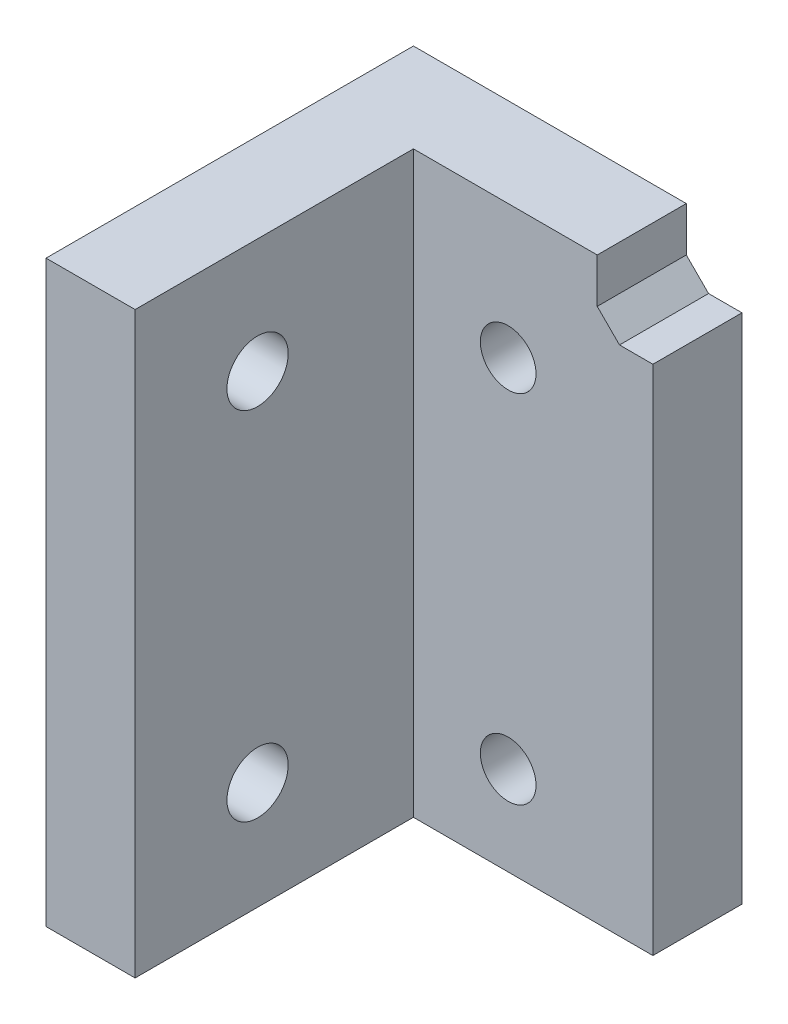
from build123d import *

# Parameters (mm, degrees)
SKETCH1_W               = 24.51
SKETCH1_H               = 148
BOSS_EXTRUDE1_DEPTH     = 8
SKETCH2_W               = 8
SKETCH2_H               = 148
BOSS_EXTRUDE2_DEPTH     = 25
SKETCH4_W               = 20.3
SKETCH4_H               = 36.8
BOSS_EXTRUDE3_DEPTH     = 8
SKETCH5_W               = 23
SKETCH5_H               = 6
BOSS_EXTRUDE4_DEPTH     = 25
CUT_EXTRUDE2_REACH      = 151.752
SKETCH6_R               = 2
RIB1_REACH              = 159.03
SKETCH8_WALL_W          = 336.456302216
SKETCH8_WALL_H          = 3
MIRROR2_COPY_1_REACH    = 159.03
MIRROR2_COPY_1_SKETCH_W = 336.456302216
MIRROR2_COPY_1_SKETCH_H = 3
SKETCH3_R               = 2.5
CUT_EXTRUDE1_DEPTH      = 10
SKETCH12_R              = 2.75
CUT_EXTRUDE3_DEPTH      = 8
SKETCH13_W              = 5
SKETCH13_H              = 46
BOSS_EXTRUDE5_DEPTH     = 8
SKETCH14_W              = 3
SKETCH14_H              = 17
BOSS_EXTRUDE6_DEPTH     = 8
CHAMFER1_SIZE           = 2
CHAMFER2_SIZE           = 6
CHAMFER2_SIZE2          = 4.047051101
SKETCH15_W              = 33
SKETCH15_H              = 96
CUT_EXTRUDE4_DEPTH      = 45


with BuildPart() as part:
    # Sketch1 → Boss-Extrude1 (new body)
    with BuildSketch(Plane.XY):
        with Locations((-12.255, 74)):
            Rectangle(SKETCH1_W, SKETCH1_H)
    extrude(amount=BOSS_EXTRUDE1_DEPTH)

    # Sketch2 → Boss-Extrude2 (add)
    with BuildSketch(Plane.XY.offset(8)):
        with Locations((-20.51, 74)):
            Rectangle(SKETCH2_W, SKETCH2_H)
    extrude(amount=BOSS_EXTRUDE2_DEPTH)

    # Sketch4 → Boss-Extrude3 (add)
    with BuildSketch(Plane(origin=(0, 0, 0), x_dir=(-1, 0, 0), z_dir=(0, 0, -1))):
        with Locations((-10.15, 129.6)):
            Rectangle(SKETCH4_W, SKETCH4_H)
    extrude(amount=-BOSS_EXTRUDE3_DEPTH)

    # Sketch5 → Boss-Extrude4 (add)
    with BuildSketch(Plane.XY.offset(8)):
        with Locations((8.8, 118.2)):
            Rectangle(SKETCH5_W, SKETCH5_H)
        with Locations((8.8, 141)):
            Rectangle(SKETCH5_W, SKETCH5_H)
    extrude(amount=BOSS_EXTRUDE4_DEPTH)

    # Cut-Extrude2: up to this face of the body (flat: up to its plane)
    cut_extrude2_end = Plane(part.part.faces().sort_by_distance((8.8, 115.2, 20.5))[0])
    # Sketch6 → Cut-Extrude2 (cut, up to the picked face)
    with BuildSketch(Plane(origin=(0, 144, 0), x_dir=(1, 0, 0), z_dir=(0, 1, 0)), mode=Mode.PRIVATE) as cut_extrude2_sk1:
        with Locations(Location((6.6, -20.5, 0), (0, 0, 270))):
            Circle(SKETCH6_R)
    cut_extrude2_tool1 = split(extrude(cut_extrude2_sk1.sketch, amount=-CUT_EXTRUDE2_REACH, mode=Mode.PRIVATE), bisect_by=cut_extrude2_end, keep=Keep.BOTH, mode=Mode.PRIVATE)
    add(cut_extrude2_tool1.solids().sort_by(Axis((6.6, 144, 20.5), (0, -1, 0)))[0], mode=Mode.SUBTRACT)

    # Sketch8 wall → Rib1 (add, up to next)
    with BuildSketch(Plane(origin=(16.3, 146, 18), x_dir=(0, -0.196116135138, 0.980580675691), z_dir=(0, -0.980580675691, -0.196116135138)), mode=Mode.PRIVATE) as rib1_sk1:
        Rectangle(SKETCH8_WALL_W, SKETCH8_WALL_H)
    rib1_tool1 = extrude(rib1_sk1.sketch, amount=RIB1_REACH, mode=Mode.PRIVATE) - part.part
    rib1 = rib1_tool1.solids().sort_by_distance((16.3, 146, 18))[0]
    add(rib1)

    # Mirror1: Rib1 across plane
    add(rib1.mirror(Plane.ZX.offset(129.6)))

    # Mirror2: Rib1 across plane
    add(rib1.mirror(Plane.ZY.offset(-7.55)))

    # Mirror2 copy 1 sketch → Mirror2 copy 1 (add, up to next)
    with BuildSketch(Plane(origin=(-1.2, 113.2, 18), x_dir=(0, 0.196116135138, 0.980580675691), z_dir=(0, 0.980580675691, -0.196116135138)), mode=Mode.PRIVATE) as mirror2_copy_1_sk1:
        Rectangle(MIRROR2_COPY_1_SKETCH_W, MIRROR2_COPY_1_SKETCH_H)
    mirror2_copy_1_tool1 = extrude(mirror2_copy_1_sk1.sketch, amount=MIRROR2_COPY_1_REACH, mode=Mode.PRIVATE) - part.part
    add(mirror2_copy_1_tool1.solids().sort_by_distance((-1.2, 113.2, 18))[0])

    # Sketch3 → Cut-Extrude1 (cut)
    with BuildSketch(Plane.XY.offset(8)):
        with Locations((-8, 8)):
            Circle(SKETCH3_R)
        with Locations((-8, 40)):
            Circle(SKETCH3_R)
        with Locations((-8, 100)):
            Circle(SKETCH3_R)
        with Locations((-8, 132)):
            Circle(SKETCH3_R)
    extrude(amount=-CUT_EXTRUDE1_DEPTH, mode=Mode.SUBTRACT)

    # Sketch12 → Cut-Extrude3 (cut)
    with BuildSketch(Plane.ZY.offset(24.51)):
        with Locations((22, 138.8)):
            Circle(SKETCH12_R)
        with Locations((22, 106.8)):
            Circle(SKETCH12_R)
        with Locations((22, 41.7)):
            Circle(SKETCH12_R)
        with Locations((22, 9.7)):
            Circle(SKETCH12_R)
    extrude(amount=-CUT_EXTRUDE3_DEPTH, mode=Mode.SUBTRACT)

    # Sketch13 → Boss-Extrude5 (add)
    with BuildSketch(Plane(origin=(0, 0, 0), x_dir=(-1, 0, 0), z_dir=(0, 0, -1))):
        with Locations((-2.5, 23)):
            Rectangle(SKETCH13_W, SKETCH13_H)
    extrude(amount=-BOSS_EXTRUDE5_DEPTH)

    # Sketch14 → Boss-Extrude6 (add)
    with BuildSketch(Plane(origin=(0, 0, 0), x_dir=(-1, 0, 0), z_dir=(0, 0, -1))):
        with Locations((-1.5, 102.7)):
            Rectangle(SKETCH14_W, SKETCH14_H)
    extrude(amount=-BOSS_EXTRUDE6_DEPTH)

    # Chamfer1
    chamfer1_edges = [part.edges().sort_by_distance(p)[0] for p in [
        (0, 46, 4),
        (3, 111.2, 4),
        (0, 94.2, 4),
    ]]
    chamfer(chamfer1_edges, length=CHAMFER1_SIZE)

    # Chamfer2
    chamfer2_edges = [part.edges().sort_by_distance(p)[0] for p in [
        (8.8, 121.2, 8),
        (8.8, 138, 8),
    ]]
    chamfer2_side = [part.faces().sort_by_distance(p)[0] for p in [
        (-4.974591741, 76.782250606, 8),
    ]]
    chamfer(chamfer2_edges, length=CHAMFER2_SIZE, length2=CHAMFER2_SIZE2, reference=chamfer2_side[0])

    # Sketch15 → Cut-Extrude4 (cut)
    with BuildSketch(Plane(origin=(20.3, 0, 0), x_dir=(0, 0, -1), z_dir=(1, 0, 0))):
        with Locations((-16.5, 100)):
            Rectangle(SKETCH15_W, SKETCH15_H)
    extrude(amount=-CUT_EXTRUDE4_DEPTH, mode=Mode.SUBTRACT)


solid = part.part
